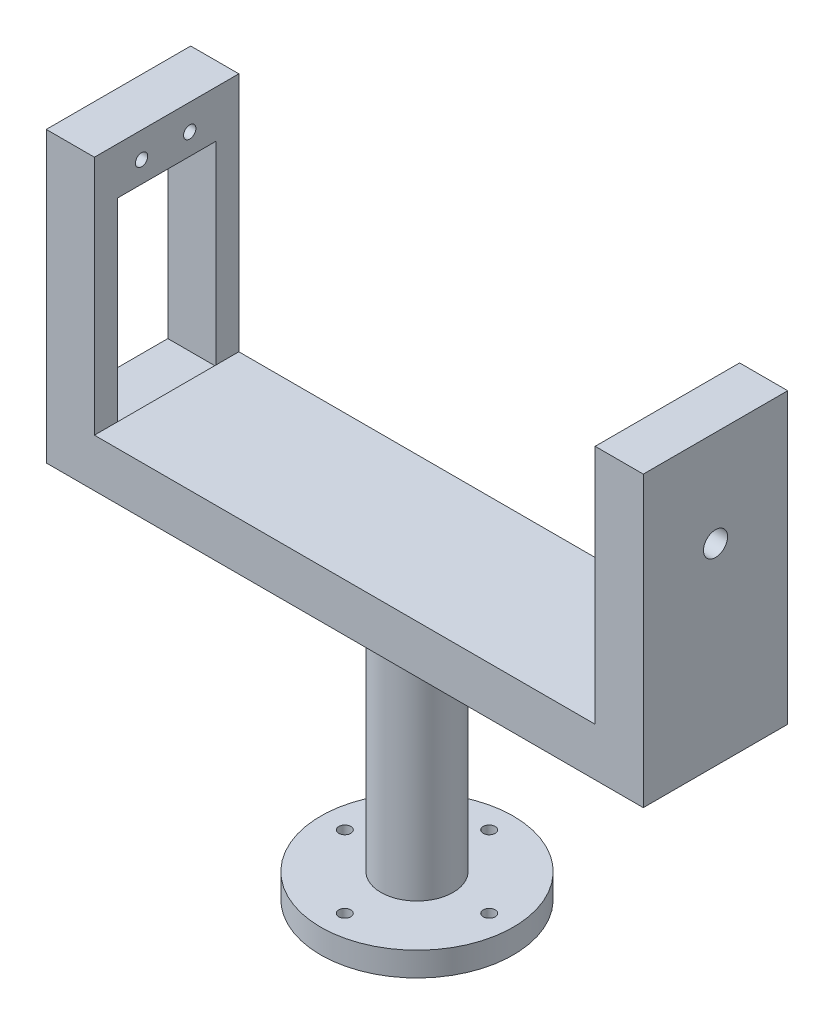
from build123d import *

# Parameters (mm, degrees)
BOSS_EXTRUDE1_DEPTH = 15
SKETCH3_R           = 7.5
BOSS_EXTRUDE2_DEPTH = 50
SKETCH4_R           = 20
SKETCH4_R_2         = 1.25
BOSS_EXTRUDE3_DEPTH = 5
SKETCH5_R           = 1.28
SKETCH5_W           = 20.5
SKETCH5_H           = 40.5
CUT_EXTRUDE1_DEPTH  = 10
SKETCH7_R           = 2.5
CUT_EXTRUDE2_DEPTH  = 10


with BuildPart() as part:
    # Sketch1 → Boss-Extrude1 (new body, symmetric)
    with BuildSketch(Plane.XY):
        Polygon((-52, 50), (-52, 0), (52, 0), (52, 50), (62, 50), (62, -10), (-62, -10), (-62, 50), align=None)
    extrude(amount=BOSS_EXTRUDE1_DEPTH, both=True)

    # Sketch3 → Boss-Extrude2 (add)
    with BuildSketch(Plane.XZ.offset(10)):
        Circle(SKETCH3_R)
    extrude(amount=BOSS_EXTRUDE2_DEPTH)

    # Sketch4 → Boss-Extrude3 (add)
    with BuildSketch(Plane.XZ.offset(60)):
        Circle(SKETCH4_R)
        with Locations((0, 15)):
            Circle(SKETCH4_R_2, mode=Mode.SUBTRACT)
        with Locations((-15, 0)):
            Circle(SKETCH4_R_2, mode=Mode.SUBTRACT)
        with Locations((15, 0)):
            Circle(SKETCH4_R_2, mode=Mode.SUBTRACT)
        with Locations((0, -15)):
            Circle(SKETCH4_R_2, mode=Mode.SUBTRACT)
    extrude(amount=BOSS_EXTRUDE3_DEPTH)

    # Sketch5 → Cut-Extrude1 (cut)
    with BuildSketch(Plane.ZY.offset(62)):
        with Locations((-4.8, 44.65)):
            Circle(SKETCH5_R)
        with Locations((5.2, 44.65)):
            Circle(SKETCH5_R)
        with Locations((-4.8, -4.537471889)):
            Circle(SKETCH5_R)
        with Locations((5.2, -4.537471889)):
            Circle(SKETCH5_R)
        with Locations((0, 20)):
            Rectangle(SKETCH5_W, SKETCH5_H)
    extrude(amount=-CUT_EXTRUDE1_DEPTH, mode=Mode.SUBTRACT)

    # Sketch7 → Cut-Extrude2 (cut)
    with BuildSketch(Plane(origin=(62, 0, 0), x_dir=(0, 0, -1), z_dir=(1, 0, 0))):
        with Locations((0, 30)):
            Circle(SKETCH7_R)
    extrude(amount=-CUT_EXTRUDE2_DEPTH, mode=Mode.SUBTRACT)


solid = part.part
